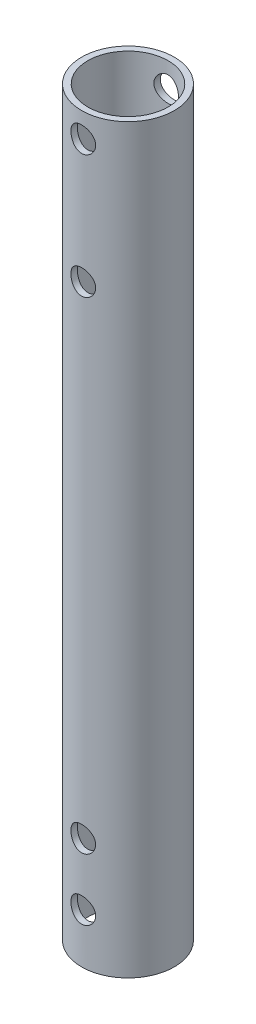
from build123d import *

# Parameters (mm, degrees)
SKETCH1_R               = 7.5
SKETCH1_R_2             = 6.5
BOSS_EXTRUDE1_DEPTH     = 120
SKETCH3_R               = 2
CUT_EXTRUDE1_DEPTH      = 8.5
CUT_EXTRUDE1_DEPTH_BACK = 8.5


with BuildPart() as part:
    # Sketch1 → Boss-Extrude1 (new body)
    with BuildSketch(Plane(origin=(0, 0, 0), x_dir=(1, 0, 0), z_dir=(0, 1, 0))):
        Circle(SKETCH1_R)
        Circle(SKETCH1_R_2, mode=Mode.SUBTRACT)
    extrude(amount=BOSS_EXTRUDE1_DEPTH)

    # Sketch3 → Cut-Extrude1 (cut, two sides)
    with BuildSketch(Plane(origin=(0, 0, 0), x_dir=(-1, 0, 0), z_dir=(0, 0, -1))) as cut_extrude1_sk:
        with Locations((0, 116)):
            Circle(SKETCH3_R)
        with Locations((0, 96)):
            Circle(SKETCH3_R)
        with Locations((0, 8)):
            Circle(SKETCH3_R)
        with Locations((0, 18)):
            Circle(SKETCH3_R)
    extrude(amount=CUT_EXTRUDE1_DEPTH, mode=Mode.SUBTRACT)
    extrude(cut_extrude1_sk.sketch, amount=-CUT_EXTRUDE1_DEPTH_BACK, mode=Mode.SUBTRACT)


solid = part.part
